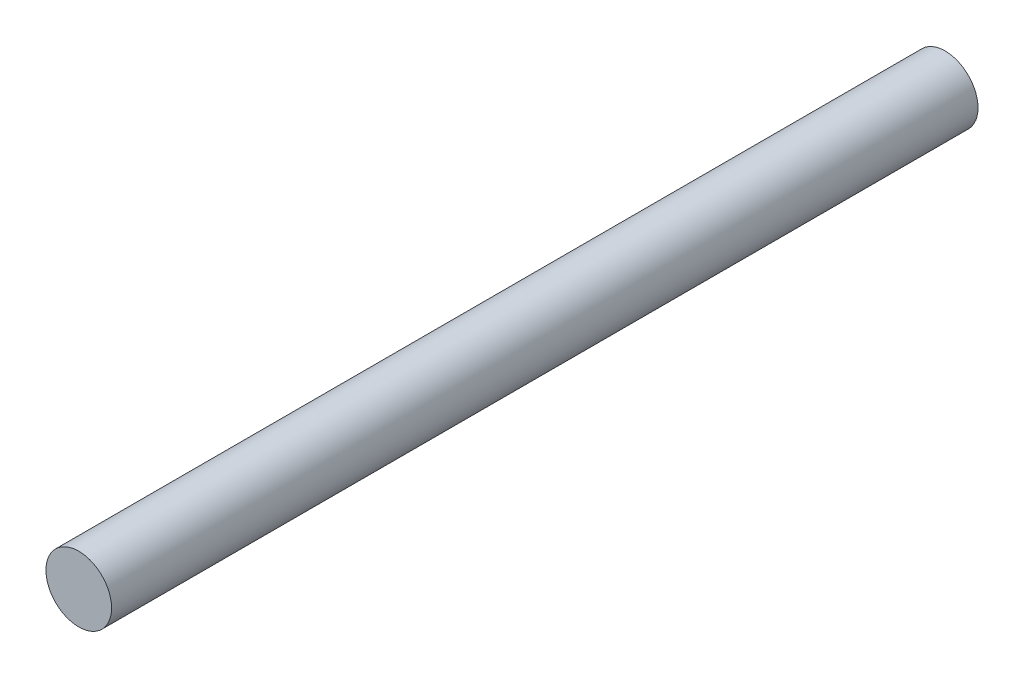
from build123d import *

# Parameters (mm, degrees)
SKETCH1_W = 2.5
SKETCH1_H = 66


with BuildPart() as part:
    # Sketch1 → Revolve1 (revolve)
    with BuildSketch(Plane(origin=(0, 0, 0), x_dir=(1, 0, 0), z_dir=(0, 1, 0))):
        with Locations((1.25, 0)):
            Rectangle(SKETCH1_W, SKETCH1_H)
    revolve(axis=Axis((0, 0, 53.783821327), (0, 0, -1)))


solid = part.part
